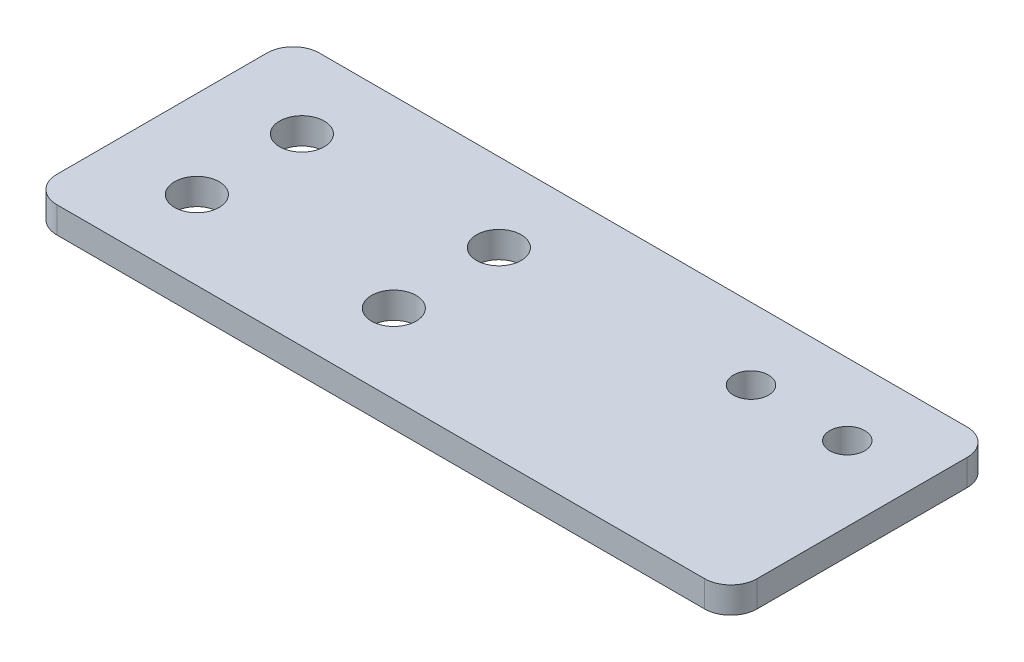
from build123d import *

# Parameters (mm, degrees)
SKETCH1_R           = 2
SKETCH1_R_2         = 2.55
BOSS_EXTRUDE2_DEPTH = 3


with BuildPart() as part:
    # Sketch1 → Boss-Extrude2 (new body)
    with BuildSketch(Plane(origin=(0, 0, 0), x_dir=(1, 0, 0), z_dir=(0, 1, 0))):
        with BuildLine():
            Line((-37, 15), (37, 15))
            ThreePointArc((37, 15), (39.121320344, 14.121320344), (40, 12))
            Line((40, 12), (40, -12))
            ThreePointArc((40, -12), (39.121320344, -14.121320344), (37, -15))
            Line((37, -15), (-37, -15))
            ThreePointArc((-37, -15), (-39.121320344, -14.121320344), (-40, -12))
            Line((-40, -12), (-40, 12))
            ThreePointArc((-40, 12), (-39.121320344, 14.121320344), (-37, 15))
        make_face()
        with Locations((20.5, 6.8)):
            Circle(SKETCH1_R, mode=Mode.SUBTRACT)
        with Locations((31.5, 6.8)):
            Circle(SKETCH1_R, mode=Mode.SUBTRACT)
        with Locations((-30, 6)):
            Circle(SKETCH1_R_2, mode=Mode.SUBTRACT)
        with Locations((-30, -6)):
            Circle(SKETCH1_R_2, mode=Mode.SUBTRACT)
        with Locations((-7.5, 6)):
            Circle(SKETCH1_R_2, mode=Mode.SUBTRACT)
        with Locations((-7.5, -6)):
            Circle(SKETCH1_R_2, mode=Mode.SUBTRACT)
    extrude(amount=BOSS_EXTRUDE2_DEPTH)


solid = part.part
